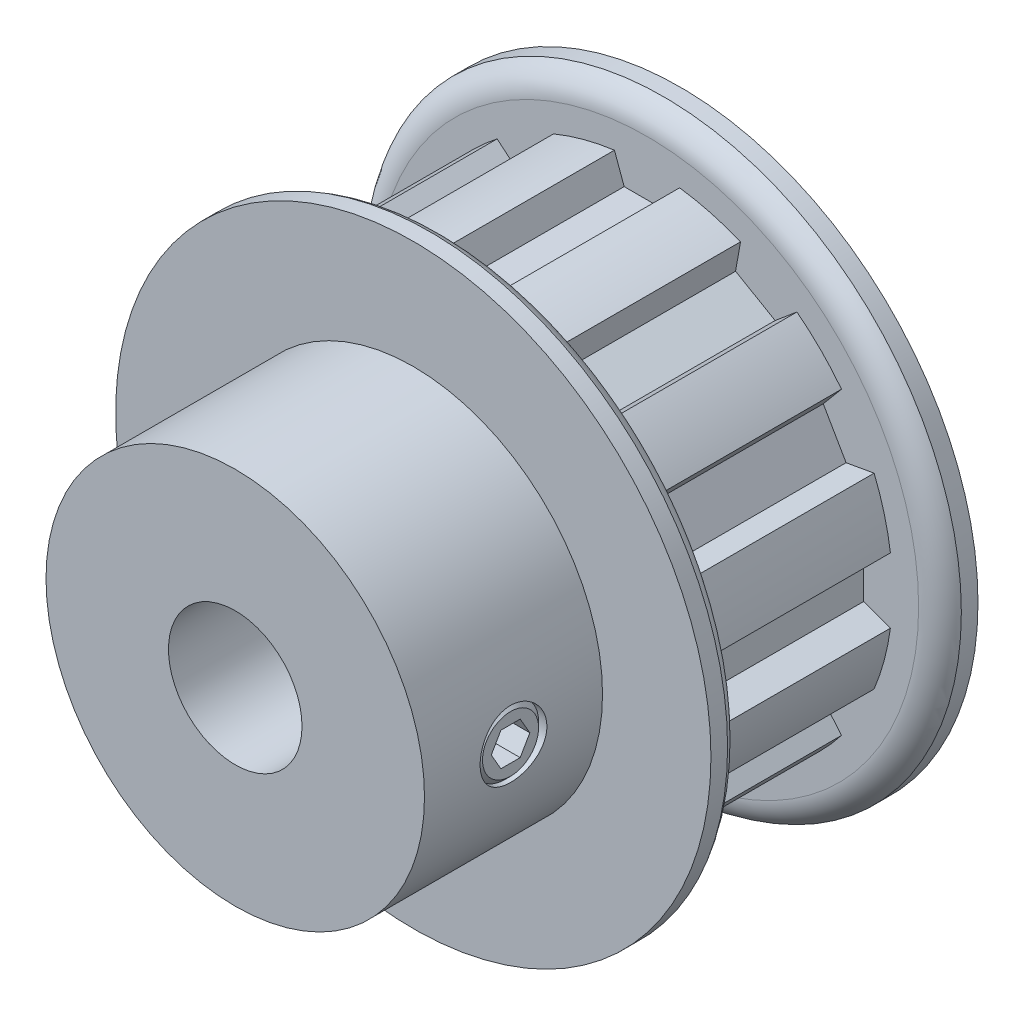
from build123d import *

# Parameters (mm, degrees)
CUT_EXTRUDE1_START = 0.8001
CUT_EXTRUDE1_DEPTH = 14.3002
CIRPATTERN1_COUNT  = 12
SKETCH4_R          = 2.38125
CUT_EXTRUDE2_DEPTH = 34.967854094
CUT_EXTRUDE3_DEPTH = 1.7859375


with BuildPart() as part:
    # Sketch2 → Revolve1 (revolve)
    with BuildSketch(Plane(origin=(0, 0, 0), x_dir=(0, 0, -1), z_dir=(1, 0, 0)), mode=Mode.PRIVATE) as revolve1_sk:
        with BuildLine():
            Line((-15.875, 4.7625), (15.875, 4.7625))
            Line((15.875, 4.7625), (15.875, 21.2344))
            Line((15.875, 21.2344), (14.68755, 21.2344))
            ThreePointArc((14.68755, 21.2344), (13.822288491, 20.478159839), (13.5001, 19.375086298))
            Line((13.5001, 19.375086298), (13.5001, 17.515772596))
            Line((13.5001, 17.515772596), (-0.8001, 17.515772596))
            Line((-0.8001, 17.515772596), (-0.8001, 19.375086298))
            ThreePointArc((-0.8001, 19.375086298), (-1.122288491, 20.478159839), (-1.98755, 21.2344))
            Line((-1.98755, 21.2344), (-3.175, 21.2344))
            Line((-3.175, 21.2344), (-3.175, 13.5001))
            Line((-3.175, 13.5001), (-15.875, 13.5001))
            Line((-15.875, 13.5001), (-15.875, 4.7625))
        make_face()
    revolve(revolve1_sk.sketch.rotate(Axis((0, 0, 15.875), (0, 0, -1)), 90), axis=Axis((0, 0, 15.875), (0, 0, -1)))

    # Sketch3 → Cut-Extrude1 (cut)
    with BuildSketch(Plane.XY.offset(CUT_EXTRUDE1_START)):
        with BuildLine():
            Line((-1.630736704, 15.4559), (1.630736704, 15.4559))
            Line((1.630736704, 15.4559), (2.3241, 17.3609))
            ThreePointArc((2.3241, 17.3609), (0, 17.515772596), (-2.3241, 17.3609))
            Line((-2.3241, 17.3609), (-1.630736704, 15.4559))
        make_face()
    cut_extrude1 = extrude(amount=-CUT_EXTRUDE1_DEPTH, mode=Mode.SUBTRACT)

    # CirPattern1: Cut-Extrude1 ×12 about axis
    cirpattern1_axis = Axis((0, 0, 0), (0, 0, 1))
    for i in range(1, CIRPATTERN1_COUNT):
        add(cut_extrude1.rotate(cirpattern1_axis, i * 360 / CIRPATTERN1_COUNT), mode=Mode.SUBTRACT)

    # Sketch4 → Cut-Extrude2 (cut, through all)
    with BuildSketch(Plane(origin=(0, 0, 0), x_dir=(0, -1, 0), z_dir=(1, 0, 0))):
        with Locations(Location((0, -9.525, 0), (0, 0, 270))):
            Circle(SKETCH4_R)
    extrude(amount=CUT_EXTRUDE2_DEPTH, mode=Mode.SUBTRACT)

    # Sketch5 → Revolve2 (revolve)
    with BuildSketch(Plane.XY.offset(9.525)):
        Polygon((4.7625, -2.00025), (4.7625, 0), (13.288429119, 0), (13.288429119, -2.00025), (12.907429119, -2.38125), (5.1435, -2.38125), align=None)
    revolve(axis=Axis((4.7625, 0, 9.525), (1, 0, 0)))

    # Sketch6 → Cut-Extrude3 (cut)
    with BuildSketch(Plane(origin=(13.288429119, 5.384140679, 0), x_dir=(0, -1, 0), z_dir=(-1, 0, 0))):
        Polygon((5.384140679, 10.899815329), (4.193515679, 10.212407664), (4.193515679, 8.837592336), (5.384140679, 8.150184671), (6.574765679, 8.837592336), (6.574765679, 10.212407664), align=None)
    extrude(amount=CUT_EXTRUDE3_DEPTH, mode=Mode.SUBTRACT)


solid = part.part
